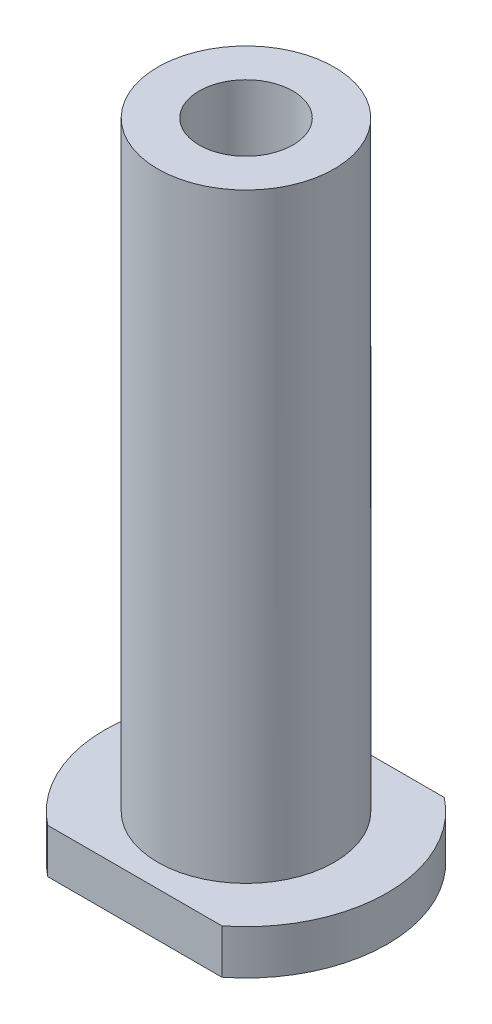
from build123d import *

# Parameters (mm, degrees)
EXTRUDE1_START              = -54
SKETCH1_R                   = 7.9375
EXTRUDE1_DEPTH              = 54
EXTRUDE4_DEPTH              = 4
F_3_8_24_TAPPED_HOLE1_D     = 8.4328
F_3_8_24_TAPPED_HOLE1_DEPTH = 24.35
F_3_8_24_TAPPED_HOLE1_TIP   = 2.533468714


with BuildPart() as part:
    # Sketch1 → Extrude1 (new body)
    with BuildSketch(Plane(origin=(0, 0, 0), x_dir=(1, 0, 0), z_dir=(0, 1, 0)).offset(EXTRUDE1_START)):
        Circle(SKETCH1_R)
    extrude(amount=EXTRUDE1_DEPTH)

    # Sketch4 → Extrude4 (add)
    with BuildSketch(Plane.XZ.offset(54)):
        with BuildLine():
            Line((-7.82879301, 10), (7.82879301, 10))
            ThreePointArc((7.82879301, 10), (12.7, 0), (7.82879301, -10))
            Line((7.82879301, -10), (-7.82879301, -10))
            ThreePointArc((-7.82879301, -10), (-12.7, 0), (-7.82879301, 10))
        make_face()
    extrude(amount=EXTRUDE4_DEPTH)

    # 3_8-24 Tapped Hole1
    with Locations(Plane(origin=(0, 0, 0), x_dir=(-1, 0, 0), z_dir=(0, 1, 0))):
        with Locations((0, 0)):
            Hole(F_3_8_24_TAPPED_HOLE1_D / 2, depth=F_3_8_24_TAPPED_HOLE1_DEPTH)
            with Locations((0, 0, -(F_3_8_24_TAPPED_HOLE1_DEPTH + F_3_8_24_TAPPED_HOLE1_TIP / 2))):  # 118° drill point
                Cone(0, F_3_8_24_TAPPED_HOLE1_D / 2, F_3_8_24_TAPPED_HOLE1_TIP, mode=Mode.SUBTRACT)


solid = part.part
